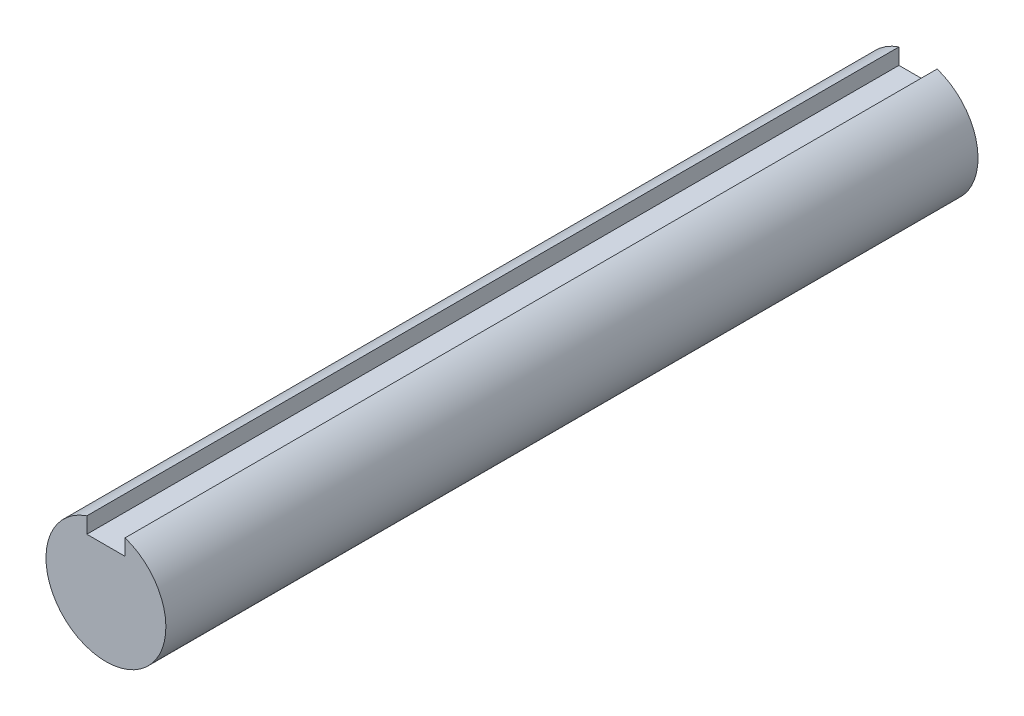
from build123d import *

# Parameters (mm, degrees)
SKETCH1_R           = 7.5
BOSS_EXTRUDE1_DEPTH = 101.6
SKETCH2_W           = 4.78
SKETCH2_H           = 2.39
CUT_EXTRUDE1_DEPTH  = 102.6


with BuildPart() as part:
    # Sketch1 → Boss-Extrude1 (new body)
    with BuildSketch(Plane.XY):
        Circle(SKETCH1_R)
    extrude(amount=BOSS_EXTRUDE1_DEPTH)

    # Sketch2 → Cut-Extrude1 (cut, through all)
    with BuildSketch(Plane.XY.offset(101.6)):
        with Locations((0, 6.305)):
            Rectangle(SKETCH2_W, SKETCH2_H)
    extrude(amount=-CUT_EXTRUDE1_DEPTH, mode=Mode.SUBTRACT)


solid = part.part
